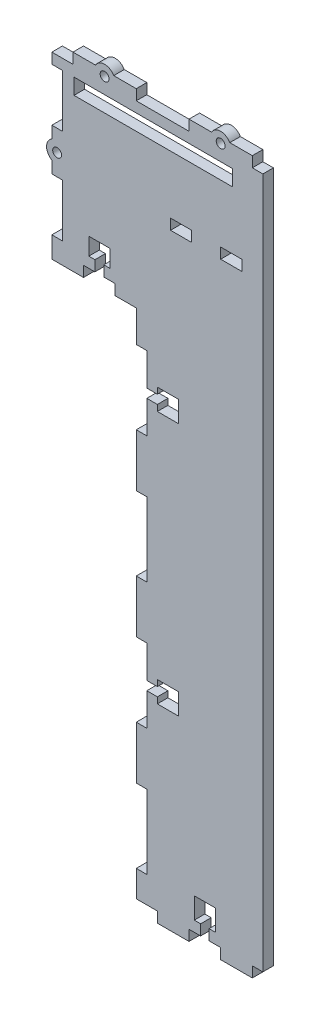
from build123d import *

# Parameters (mm, degrees)
SKETCH1_W           = 106
SKETCH1_H           = 327.5
BOSS_EXTRUDE1_DEPTH = 5
SKETCH2_W           = 40
SKETCH2_H           = 242.5
CUT_EXTRUDE1_DEPTH  = 5
SKETCH3_W           = 5
SKETCH3_H           = 25
CUT_EXTRUDE2_DEPTH  = 5
SKETCH4_W           = 30
SKETCH4_H           = 5
BOSS_EXTRUDE2_DEPTH = 5
SKETCH5_W           = 15
SKETCH5_H           = 5
CUT_EXTRUDE3_DEPTH  = 5
SKETCH6_W           = 5
SKETCH6_H           = 35
CUT_EXTRUDE4_DEPTH  = 5
SKETCH7_W           = 10
SKETCH7_H           = 5
CUT_EXTRUDE5_DEPTH  = 5
SKETCH8_W           = 15
SKETCH8_H           = 5
BOSS_EXTRUDE3_DEPTH = 5
SKETCH9_W           = 70
SKETCH9_H           = 7.5
CUT_EXTRUDE6_DEPTH  = 5
SKETCH10_W          = 5
SKETCH10_H          = 227.5
BOSS_EXTRUDE4_DEPTH = 5
SKETCH11_R          = 2.1
CUT_EXTRUDE7_DEPTH  = 5
BOSS_EXTRUDE5_DEPTH = 5
SKETCH13_W          = 10
SKETCH13_H          = 327.5
SKETCH13_W_2        = 11.118393302
SKETCH13_H_2        = 31.265749724
SKETCH13_W_3        = 24.993123917
SKETCH13_H_3        = 36.030112223
CUT_EXTRUDE8_DEPTH  = 10
SKETCH14_W          = 5
SKETCH14_H          = 327.5
CUT_EXTRUDE9_DEPTH  = 1
SKETCH15_W          = 4.2
SKETCH15_H          = 5
SKETCH15_W_2        = 5
SKETCH15_H_2        = 4.2
SKETCH15_W_3        = 10
SKETCH15_H_3        = 10
CUT_EXTRUDE10_DEPTH = 10
SKETCH16_R          = 2.1
CUT_EXTRUDE11_DEPTH = 10
BOSS_EXTRUDE6_DEPTH = 5
SKETCH19_W          = 4
SKETCH19_H          = 5
CUT_EXTRUDE13_DEPTH = 5
SKETCH20_R          = 2.1
CUT_EXTRUDE14_DEPTH = 5
BOSS_EXTRUDE7_DEPTH = 5
SKETCH22_W          = 5
SKETCH22_H          = 7.5
CUT_EXTRUDE15_DEPTH = 5


with BuildPart() as part:
    # Sketch1 → Boss-Extrude1 (new body)
    with BuildSketch(Plane.XY):
        with Locations((-53, 163.75)):
            Rectangle(SKETCH1_W, SKETCH1_H)
    extrude(amount=BOSS_EXTRUDE1_DEPTH)

    # Sketch2 → Cut-Extrude1 (cut)
    with BuildSketch(Plane.XY.offset(5)):
        with Locations((-86, 121.25)):
            Rectangle(SKETCH2_W, SKETCH2_H)
    extrude(amount=-CUT_EXTRUDE1_DEPTH, mode=Mode.SUBTRACT)

    # Sketch3 → Cut-Extrude2 (cut)
    with BuildSketch(Plane.XY.offset(5)):
        with Locations((-103.5, 310)):
            Rectangle(SKETCH3_W, SKETCH3_H)
        with Locations((-103.5, 265)):
            Rectangle(SKETCH3_W, SKETCH3_H)
    extrude(amount=-CUT_EXTRUDE2_DEPTH, mode=Mode.SUBTRACT)

    # Sketch4 → Boss-Extrude2 (add)
    with BuildSketch(Plane.XY.offset(5)):
        with Locations((-26, 330)):
            Rectangle(SKETCH4_W, SKETCH4_H)
        with Locations((-81, 330)):
            Rectangle(SKETCH4_W, SKETCH4_H)
    extrude(amount=-BOSS_EXTRUDE2_DEPTH)

    # Sketch5 → Cut-Extrude3 (cut)
    with BuildSketch(Plane.XY.offset(5)):
        with Locations((-83.5, 245)):
            Rectangle(SKETCH5_W, SKETCH5_H)
    extrude(amount=-CUT_EXTRUDE3_DEPTH, mode=Mode.SUBTRACT)

    # Sketch6 → Cut-Extrude4 (cut)
    with BuildSketch(Plane.XY.offset(5)):
        with Locations((-63.5, 210)):
            Rectangle(SKETCH6_W, SKETCH6_H)
        with Locations((-63.5, 150)):
            Rectangle(SKETCH6_W, SKETCH6_H)
        with Locations((-63.5, 90)):
            Rectangle(SKETCH6_W, SKETCH6_H)
        with Locations((-63.5, 30)):
            Rectangle(SKETCH6_W, SKETCH6_H)
    extrude(amount=-CUT_EXTRUDE4_DEPTH, mode=Mode.SUBTRACT)

    # Sketch7 → Cut-Extrude5 (cut)
    with BuildSketch(Plane.XY.offset(5)):
        with Locations((-21, 285)):
            Rectangle(SKETCH7_W, SKETCH7_H)
        with Locations((-44.75, 285)):
            Rectangle(SKETCH7_W, SKETCH7_H)
    extrude(amount=-CUT_EXTRUDE5_DEPTH, mode=Mode.SUBTRACT)

    # Sketch8 → Boss-Extrude3 (add)
    with BuildSketch(Plane.XY.offset(5)):
        with Locations((-18.5, -2.5)):
            Rectangle(SKETCH8_W, SKETCH8_H)
        with Locations((-48.5, -2.5)):
            Rectangle(SKETCH8_W, SKETCH8_H)
    extrude(amount=-BOSS_EXTRUDE3_DEPTH)

    # Sketch9 → Cut-Extrude6 (cut)
    with BuildSketch(Plane(origin=(0, 0, 0), x_dir=(-1, 0, 0), z_dir=(0, 0, -1))):
        with Locations((55.5, 318.75)):
            Rectangle(SKETCH9_W, SKETCH9_H)
    extrude(amount=-CUT_EXTRUDE6_DEPTH, mode=Mode.SUBTRACT)

    # Sketch10 → Boss-Extrude4 (add)
    with BuildSketch(Plane(origin=(0, 0, 0), x_dir=(-1, 0, 0), z_dir=(0, 0, -1))):
        with Locations((-2.5, 163.75)):
            Rectangle(SKETCH10_W, SKETCH10_H)
    extrude(amount=-BOSS_EXTRUDE4_DEPTH)

    # Sketch11 → Cut-Extrude7 (cut)
    with BuildSketch(Plane(origin=(0, 0, 0), x_dir=(-1, 0, 0), z_dir=(0, 0, -1))):
        with Locations((-2.5, 75)):
            Circle(SKETCH11_R)
        with Locations((-2.5, 252.5)):
            Circle(SKETCH11_R)
    extrude(amount=-CUT_EXTRUDE7_DEPTH, mode=Mode.SUBTRACT)

    # Sketch12 → Boss-Extrude5 (add)
    with BuildSketch(Plane(origin=(0, 0, 0), x_dir=(-1, 0, 0), z_dir=(0, 0, -1))):
        with BuildLine():
            Line((-5, 70.669872981), (-5, 79.330127019))
            ThreePointArc((-5, 79.330127019), (-7.5, 75), (-5, 70.669872981))
        make_face()
        with BuildLine():
            Line((-5, 256.830127019), (-5, 248.169872981))
            ThreePointArc((-5, 248.169872981), (-7.5, 252.5), (-5, 256.830127019))
        make_face()
    extrude(amount=-BOSS_EXTRUDE5_DEPTH)

    # Sketch13 → Cut-Extrude8 (cut)
    with BuildSketch(Plane(origin=(0, 0, 0), x_dir=(-1, 0, 0), z_dir=(0, 0, -1))):
        with Locations((0, 163.75)):
            Rectangle(SKETCH13_W, SKETCH13_H)
        with Locations((-10.559196651, 252.176794505)):
            Rectangle(SKETCH13_W_2, SKETCH13_H_2)
        with Locations((-17.496561959, 79.007982861)):
            Rectangle(SKETCH13_W_3, SKETCH13_H_3)
    extrude(amount=-CUT_EXTRUDE8_DEPTH, mode=Mode.SUBTRACT)

    # Sketch14 → Cut-Extrude9 (cut)
    with BuildSketch(Plane(origin=(-5, 0, 0), x_dir=(0, 0, -1), z_dir=(1, 0, 0))):
        with Locations((-2.5, 163.75)):
            Rectangle(SKETCH14_W, SKETCH14_H)
    extrude(amount=-CUT_EXTRUDE9_DEPTH, mode=Mode.SUBTRACT)

    # Sketch15 → Cut-Extrude10 (cut)
    with BuildSketch(Plane(origin=(0, 0, 0), x_dir=(-1, 0, 0), z_dir=(0, 0, -1))):
        Polygon((78.5, 252.5), (81.4, 252.5), (85.6, 252.5), (88.5, 252.5), (88.5, 260.7), (78.5, 260.7), align=None)
        with Locations((83.5, 250)):
            Rectangle(SKETCH15_W, SKETCH15_H)
        Polygon((56, 207.9), (56, 212.1), (56, 215), (46, 215), (46, 205), (56, 205), align=None)
        with Locations((58.5, 210)):
            Rectangle(SKETCH15_W_2, SKETCH15_H_2)
        with Locations((51, 90)):
            Rectangle(SKETCH15_W_3, SKETCH15_H_3)
        with Locations((58.5, 90)):
            Rectangle(SKETCH15_W_2, SKETCH15_H_2)
    extrude(amount=-CUT_EXTRUDE10_DEPTH, mode=Mode.SUBTRACT)

    # Sketch16 → Cut-Extrude11 (cut)
    with BuildSketch(Plane(origin=(0, 0, 0), x_dir=(-1, 0, 0), z_dir=(0, 0, -1))):
        with Locations((103.5, 287.5)):
            Circle(SKETCH16_R)
    extrude(amount=-CUT_EXTRUDE11_DEPTH, mode=Mode.SUBTRACT)

    # Sketch17 → Boss-Extrude6 (add)
    with BuildSketch(Plane(origin=(0, 0, 0), x_dir=(-1, 0, 0), z_dir=(0, 0, -1))):
        with BuildLine():
            Line((106, 283.169872981), (106, 291.830127019))
            ThreePointArc((106, 291.830127019), (108.5, 287.5), (106, 283.169872981))
        make_face()
    extrude(amount=-BOSS_EXTRUDE6_DEPTH)

    # Sketch19 → Cut-Extrude13 (cut)
    with BuildSketch(Plane.XY.offset(5)):
        with Locations((-33.5, 2.5)):
            Rectangle(SKETCH19_W, SKETCH19_H)
        Polygon((-38.5, 5), (-35.5, 5), (-31.5, 5), (-28.5, 5), (-28.5, 15), (-38.5, 15), align=None)
    extrude(amount=-CUT_EXTRUDE13_DEPTH, mode=Mode.SUBTRACT)

    # Sketch20 → Cut-Extrude14 (cut)
    with BuildSketch(Plane(origin=(0, 0, 0), x_dir=(-1, 0, 0), z_dir=(0, 0, -1))):
        with Locations((26, 330)):
            Circle(SKETCH20_R)
        with Locations((81, 330)):
            Circle(SKETCH20_R)
    extrude(amount=-CUT_EXTRUDE14_DEPTH, mode=Mode.SUBTRACT)

    # Sketch21 → Boss-Extrude7 (add)
    with BuildSketch(Plane(origin=(0, 0, 0), x_dir=(-1, 0, 0), z_dir=(0, 0, -1))):
        with BuildLine():
            Line((30.330127019, 332.5), (21.669872981, 332.5))
            ThreePointArc((21.669872981, 332.5), (26, 335), (30.330127019, 332.5))
        make_face()
        with BuildLine():
            Line((76.669872981, 332.5), (85.330127019, 332.5))
            ThreePointArc((85.330127019, 332.5), (81, 335), (76.669872981, 332.5))
        make_face()
    extrude(amount=-BOSS_EXTRUDE7_DEPTH)

    # Sketch22 → Cut-Extrude15 (cut)
    with BuildSketch(Plane(origin=(0, 0, 0), x_dir=(-1, 0, 0), z_dir=(0, 0, -1))):
        with Locations((93, 318.75)):
            Rectangle(SKETCH22_W, SKETCH22_H)
    extrude(amount=-CUT_EXTRUDE15_DEPTH, mode=Mode.SUBTRACT)


solid = part.part
